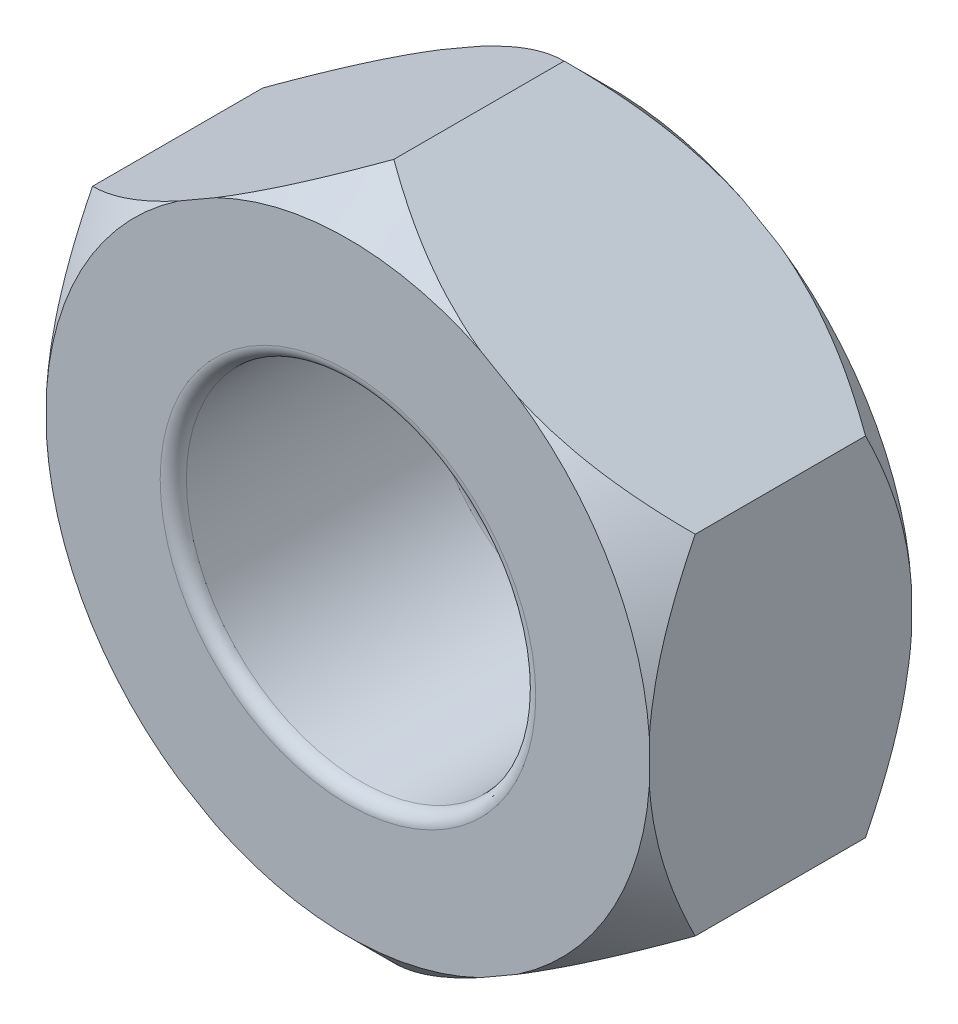
from build123d import *

# Parameters (mm, degrees)
EXTRUDE_1_DEPTH     = 6
SKETCH_2_R          = 4
CUT_EXTRUDE_1_DEPTH = 6
FILLET_3_R          = 0.3


with BuildPart() as part:
    # 草图1 → 凸台-拉伸1 (new body)
    with BuildSketch(Plane.XY):
        Polygon((0, 7.967433715), (-6.9, 3.983716857), (-6.9, -3.983716857), (0, -7.967433715), (6.9, -3.983716857), (6.9, 3.983716857), align=None)
    extrude(amount=-EXTRUDE_1_DEPTH)

    # 草图2 → 切除-拉伸1 (cut)
    with BuildSketch(Plane.XY):
        Circle(SKETCH_2_R)
    extrude(amount=-CUT_EXTRUDE_1_DEPTH, mode=Mode.SUBTRACT)

    # 草图3 → 切除-旋转2 (revolve, cut)
    with BuildSketch(Plane(origin=(0, 0, 0), x_dir=(0, 0, -1), z_dir=(1, 0, 0))):
        Polygon((0, -7.967433715), (1.05, -7.967433715), (0, -6.917433715), align=None)
        Polygon((6, -7.967433715), (4.95, -7.967433715), (6, -6.917433715), align=None)
    revolve(axis=Axis((0, 0, 0), (0, 0, -1)), mode=Mode.SUBTRACT)

    # 圆角3
    fillet_3_edges = [part.edges().sort_by_distance(p)[0] for p in [
        (-4, 0, -6),
        (-4, 0, 0),
    ]]
    fillet(fillet_3_edges, radius=FILLET_3_R)


solid = part.part
